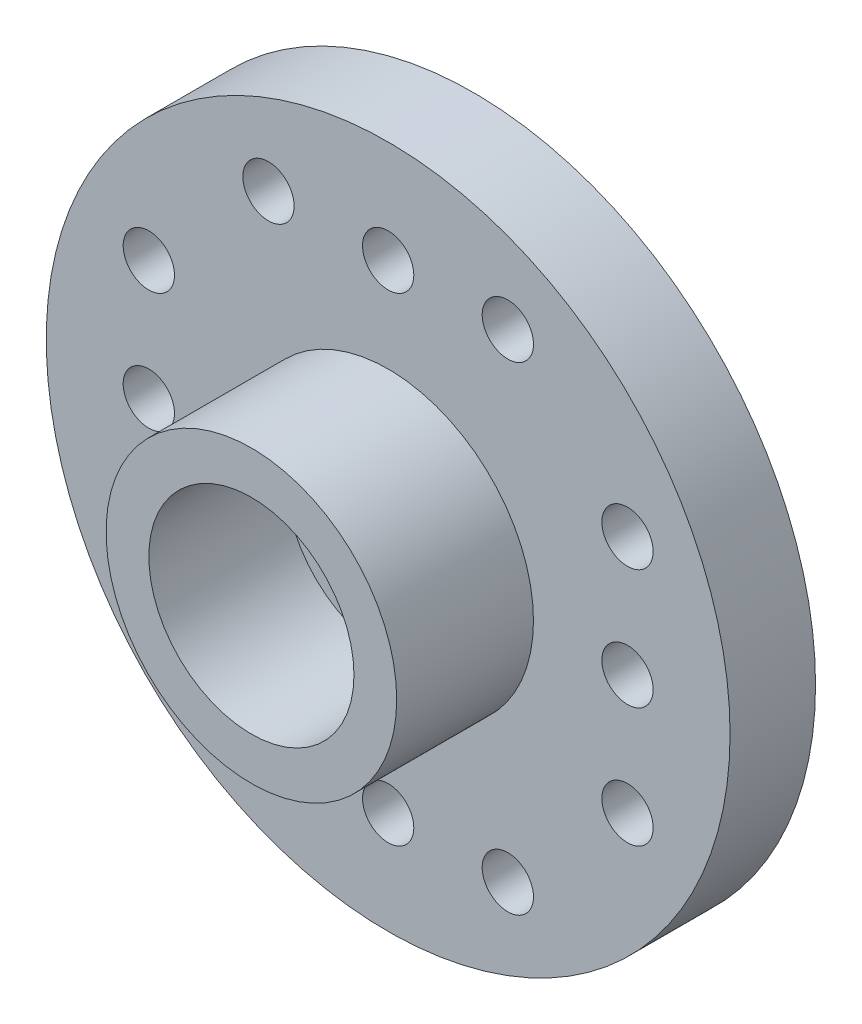
from build123d import *

# Parameters (mm, degrees)
SKETCH1_R           = 10
SKETCH1_R_2         = 0.75
SKETCH1_R_3         = 1.5
BOSS_EXTRUDE1_DEPTH = 2.5
SKETCH5_R           = 4.25
SKETCH5_R_2         = 3
BOSS_EXTRUDE2_DEPTH = 4


with BuildPart() as part:
    # Sketch1 → Boss-Extrude1 (new body)
    with BuildSketch(Plane.XY):
        Circle(SKETCH1_R)
        with Locations((-7, 0)):
            Circle(SKETCH1_R_2, mode=Mode.SUBTRACT)
        with Locations((3.5, 7)):
            Circle(SKETCH1_R_2, mode=Mode.SUBTRACT)
        with Locations((0, 7)):
            Circle(SKETCH1_R_2, mode=Mode.SUBTRACT)
        with Locations((-3.5, 7)):
            Circle(SKETCH1_R_2, mode=Mode.SUBTRACT)
        with Locations((7, -3.5)):
            Circle(SKETCH1_R_2, mode=Mode.SUBTRACT)
        with Locations((7, 0)):
            Circle(SKETCH1_R_2, mode=Mode.SUBTRACT)
        with Locations((7, 3.5)):
            Circle(SKETCH1_R_2, mode=Mode.SUBTRACT)
        with Locations((-3.5, -7)):
            Circle(SKETCH1_R_2, mode=Mode.SUBTRACT)
        with Locations((0, -7)):
            Circle(SKETCH1_R_2, mode=Mode.SUBTRACT)
        with Locations((3.5, -7)):
            Circle(SKETCH1_R_2, mode=Mode.SUBTRACT)
        with Locations((-7, -3.5)):
            Circle(SKETCH1_R_2, mode=Mode.SUBTRACT)
        with Locations((-7, 3.5)):
            Circle(SKETCH1_R_2, mode=Mode.SUBTRACT)
        Circle(SKETCH1_R_3, mode=Mode.SUBTRACT)
    extrude(amount=BOSS_EXTRUDE1_DEPTH)

    # Sketch5 → Boss-Extrude2 (add)
    with BuildSketch(Plane.XY.offset(2.5)):
        Circle(SKETCH5_R)
        Circle(SKETCH5_R_2, mode=Mode.SUBTRACT)
    extrude(amount=BOSS_EXTRUDE2_DEPTH)


solid = part.part
